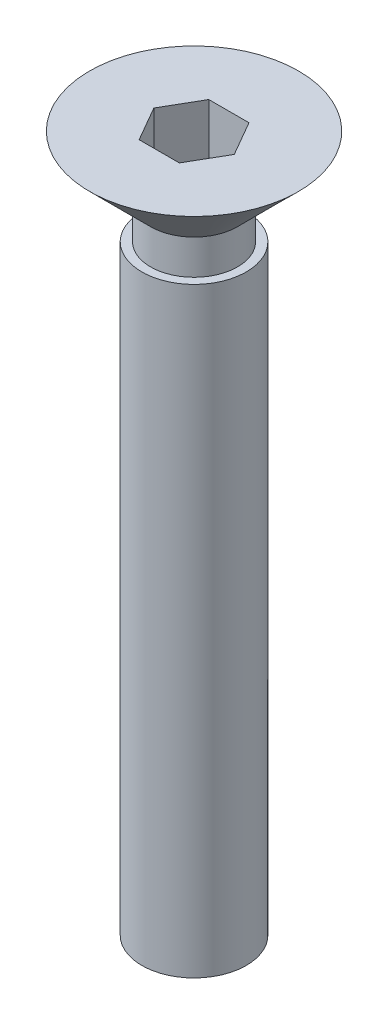
from build123d import *

# Parameters (mm, degrees)
CUT_EXTRUDE_1_DEPTH = 2


with BuildPart() as part:
    # 草图1 → 旋转1 (revolve)
    with BuildSketch(Plane.XY):
        Polygon((0, 20), (-3, 20), (-1.25, 18.25), (-1.25, 17.25), (-1.5, 17.25), (-1.5, 0), (0, 0), align=None)
    revolve(axis=Axis((0, 0, 0), (0, 1, 0)))

    # 草图2 → 切除-拉伸1 (cut)
    with BuildSketch(Plane(origin=(0, 20, 0), x_dir=(1, 0, 0), z_dir=(0, 1, 0))):
        Polygon((0.577350269, 1), (-0.577350269, 1), (-1.154700538, 0), (-0.577350269, -1), (0.577350269, -1), (1.154700538, 0), align=None)
    extrude(amount=-CUT_EXTRUDE_1_DEPTH, mode=Mode.SUBTRACT)


solid = part.part
